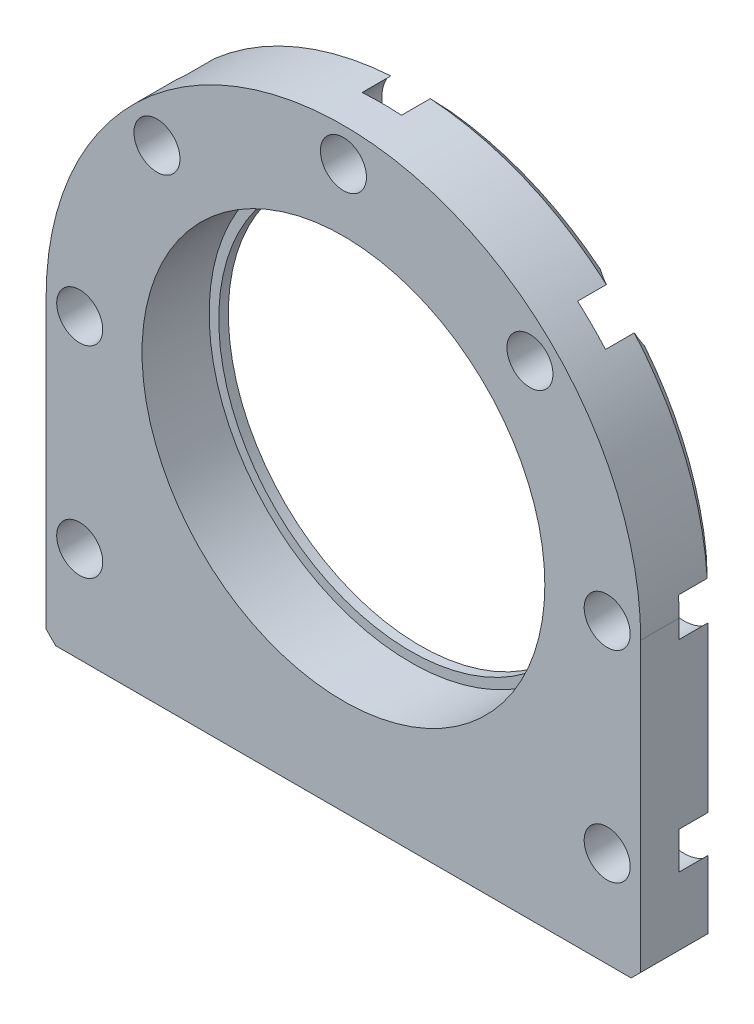
from build123d import *

# Parameters (mm, degrees)
EXTRUDE_1_DEPTH              = 8
CHAMFER_1_SIZE               = 1
HOLE_WIZARD_M4_1_D           = 4.8
HOLE_WIZARD_M4_1_CBORE_D     = 8
HOLE_WIZARD_M4_1_CBORE_DEPTH = 4
PATTERN_CIRCULAR_1_COUNT     = 8
SKETCH_11_R                  = 21
CUT_EXTRUDE_8_DEPTH          = 7
SKETCH_12_R                  = 20
CUT_EXTRUDE_9_DEPTH          = 2.0000001
HOLE_WIZARD_M4_2_D           = 4.8
HOLE_WIZARD_M4_2_CBORE_D     = 8
HOLE_WIZARD_M4_2_CBORE_DEPTH = 4


with BuildPart() as part:
    # ｽｹｯﾁ1 → ﾎﾞｽ - 押し出し1 (new body)
    with BuildSketch(Plane.XY):
        with BuildLine():
            Line((31, -31), (-31, -31))
            Line((-31, -31), (-31, 0))
            ThreePointArc((-31, 0), (0, 31), (31, 0))
            Line((31, 0), (31, -31))
        make_face()
    extrude(amount=EXTRUDE_1_DEPTH)

    # 面取り1
    chamfer_1_edges = [part.edges().sort_by_distance(p)[0] for p in [
        (31, -15.5, 0),
        (0, -31, 0),
        (-31, -15.5, 0),
        (0, 31, 0),
        (31, -31, 4),
        (-31, -31, 4),
    ]]
    chamfer(chamfer_1_edges, length=CHAMFER_1_SIZE)

    # M4 穴付きねじ用座ぐり穴1 (through all)
    with Locations(Plane(origin=(0, 0, 0), x_dir=(1, 0, 0), z_dir=(0, 0, -1))):
        with Locations((0, -27.5)):
            hole_wizard_m4_1 = CounterBoreHole(HOLE_WIZARD_M4_1_D / 2, HOLE_WIZARD_M4_1_CBORE_D / 2, HOLE_WIZARD_M4_1_CBORE_DEPTH)

    # 円形ﾊﾟﾀｰﾝ1: M4 穴付きねじ用座ぐり穴1 ×8 about axis, 3 skipped
    pattern_circular_1_axis = Axis((0, 0, 0), (0, 0, -1))
    add([hole_wizard_m4_1.rotate(pattern_circular_1_axis, i * 360 / PATTERN_CIRCULAR_1_COUNT) for i in range(1, PATTERN_CIRCULAR_1_COUNT) if i not in (3, 4, 5)], mode=Mode.SUBTRACT)

    # ｽｹｯﾁ11 → ｶｯﾄ - 押し出し8 (cut)
    with BuildSketch(Plane.XY.offset(8)):
        Circle(SKETCH_11_R)
    extrude(amount=-CUT_EXTRUDE_8_DEPTH, mode=Mode.SUBTRACT)

    # ｽｹｯﾁ12 → ｶｯﾄ - 押し出し9 (cut, through all)
    with BuildSketch(Plane.XY.offset(1)):
        Circle(SKETCH_12_R)
    extrude(amount=-CUT_EXTRUDE_9_DEPTH, mode=Mode.SUBTRACT)

    # M4 穴付きねじ用座ぐり穴2 (through all)
    with Locations(Plane(origin=(0, 0, 0), x_dir=(-1, 0, 0), z_dir=(0, 0, -1))):
        with Locations((27.5, -21), (-27.5, -21)):
            CounterBoreHole(HOLE_WIZARD_M4_2_D / 2, HOLE_WIZARD_M4_2_CBORE_D / 2, HOLE_WIZARD_M4_2_CBORE_DEPTH)


solid = part.part
